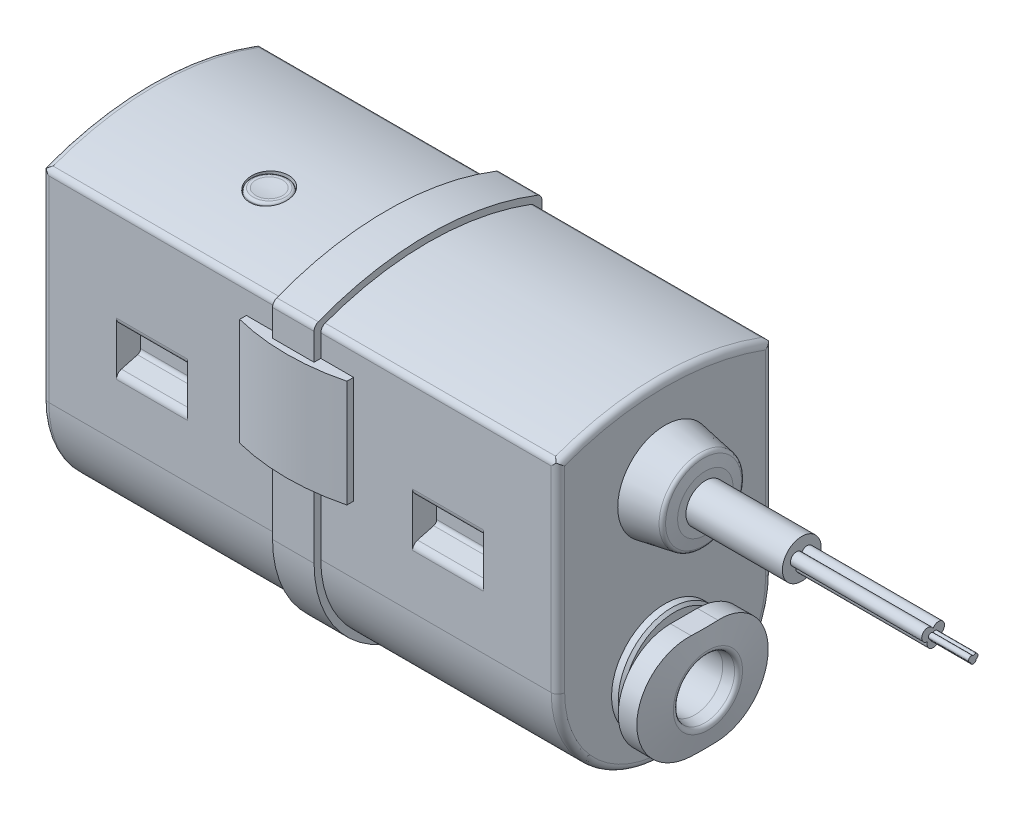
from build123d import *

# Parameters (mm, degrees)
BOSS_EXTRUDE1_DEPTH          = 19.25
BOSS_EXTRUDE1_DEPTH_BACK     = 19.25
CUT_EXTRUDE1_DEPTH           = 25
CUT_EXTRUDE2_DEPTH           = 25
CUT_REVOLVE1_ANGLE           = 90
CUT_REVOLVE1_OTHER_WAY_ANGLE = 90
CUT_REVOLVE2_ANGLE           = 90
CUT_REVOLVE2_OTHER_WAY_ANGLE = 90
CUT_REVOLVE3_ANGLE           = 45
CUT_REVOLVE3_OTHER_WAY_ANGLE = 45
CUT_REVOLVE4_ANGLE           = 45
CUT_REVOLVE4_OTHER_WAY_ANGLE = 45
CUT_EXTRUDE3_DEPTH           = 5.3
CUT_EXTRUDE4_DEPTH           = 5.3
CUT_EXTRUDE5_DEPTH           = 5.3
CUT_EXTRUDE6_DEPTH           = 5.3
BOSS_EXTRUDE2_DEPTH          = 1.55
BOSS_EXTRUDE2_DEPTH_BACK     = 1.55
SKETCH14_W                   = 12
SKETCH14_H                   = 12
CUT_EXTRUDE7_DEPTH           = 2
SKETCH16_W                   = 12
SKETCH16_H                   = 12
CUT_EXTRUDE8_DEPTH           = 2
BOSS_EXTRUDE3_DEPTH          = 4
BOSS_EXTRUDE3_DEPTH_BACK     = 4
BOSS_EXTRUDE4_DEPTH          = 4
BOSS_EXTRUDE4_DEPTH_BACK     = 4
SKETCH19_W                   = 1.45
SKETCH19_H                   = 5
BOSS_EXTRUDE5_DEPTH          = 9.8
BOSS_EXTRUDE6_DEPTH          = 3


with BuildPart() as part:
    # Sketch1 → Boss-Extrude1 (new body, two sides)
    with BuildSketch(Plane(origin=(0, 0, 0), x_dir=(0, 0, -1), z_dir=(1, 0, 0))) as boss_extrude1_sk:
        with BuildLine():
            Line((8, 8), (8, 22.64944168))
            ThreePointArc((8, 22.64944168), (7.910614967, 22.934740381), (7.674418605, 23.118033347))
            ThreePointArc((7.674418605, 23.118033347), (0, 24.5), (-7.674418605, 23.118033347))
            ThreePointArc((-7.674418605, 23.118033347), (-7.910614967, 22.934740381), (-8, 22.64944168))
            Line((-8, 22.64944168), (-8, 8))
            ThreePointArc((-8, 8), (0, 0), (8, 8))
        make_face()
    extrude(amount=BOSS_EXTRUDE1_DEPTH)
    extrude(boss_extrude1_sk.sketch, amount=-BOSS_EXTRUDE1_DEPTH_BACK)

    # Sketch2 → Cut-Extrude1 (cut)
    with BuildSketch(Plane(origin=(0, 0, 0), x_dir=(1, 0, 0), z_dir=(0, 1, 0))):
        with BuildLine():
            Line((0, 18), (0, 8))
            Line((0, 8), (18.75, 8))
            ThreePointArc((18.75, 8), (19.103553391, 7.853553391), (19.25, 7.5))
            Line((19.25, 7.5), (19.25, -7.5))
            ThreePointArc((19.25, -7.5), (19.103553391, -7.853553391), (18.75, -8))
            Line((18.75, -8), (0, -8))
            Line((0, -8), (0, -18))
            Line((0, -18), (29.25, -18))
            Line((29.25, -18), (29.25, 18))
            Line((29.25, 18), (0, 18))
        make_face()
    extrude(amount=CUT_EXTRUDE1_DEPTH, mode=Mode.SUBTRACT)

    # Sketch3 → Cut-Extrude2 (cut)
    with BuildSketch(Plane(origin=(0, 0, 0), x_dir=(1, 0, 0), z_dir=(0, 1, 0))):
        with BuildLine():
            Line((-29.25, 18), (-29.25, -18))
            Line((-29.25, -18), (0, -18))
            Line((0, -18), (0, -8))
            Line((0, -8), (-18.75, -8))
            ThreePointArc((-18.75, -8), (-19.103553391, -7.853553391), (-19.25, -7.5))
            Line((-19.25, -7.5), (-19.25, 7.5))
            ThreePointArc((-19.25, 7.5), (-19.103553391, 7.853553391), (-18.75, 8))
            Line((-18.75, 8), (0, 8))
            Line((0, 8), (0, 18))
            Line((0, 18), (-29.25, 18))
        make_face()
    extrude(amount=CUT_EXTRUDE2_DEPTH, mode=Mode.SUBTRACT)

    # Sketch4 → Cut-Revolve1 (revolve, cut)
    with BuildSketch(Plane.XY):
        with BuildLine():
            Line((-25, 3), (-25, -5.003376947))
            Line((-25, -5.003376947), (-14, -5.003376947))
            Line((-14, -5.003376947), (-14, 0))
            Line((-14, 0), (-18.75, 0))
            ThreePointArc((-18.75, 0), (-19.103553391, 0.146446609), (-19.25, 0.5))
            Line((-19.25, 0.5), (-19.25, 3))
            Line((-19.25, 3), (-25, 3))
        make_face()
    revolve(axis=Axis((-2, 8, 0), (1, 0, 0)), revolution_arc=CUT_REVOLVE1_ANGLE, mode=Mode.SUBTRACT)

    # Sketch4 → Cut-Revolve1 other way (revolve, cut)
    with BuildSketch(Plane.XY):
        with BuildLine():
            Line((-25, 3), (-25, -5.003376947))
            Line((-25, -5.003376947), (-14, -5.003376947))
            Line((-14, -5.003376947), (-14, 0))
            Line((-14, 0), (-18.75, 0))
            ThreePointArc((-18.75, 0), (-19.103553391, 0.146446609), (-19.25, 0.5))
            Line((-19.25, 0.5), (-19.25, 3))
            Line((-19.25, 3), (-25, 3))
        make_face()
    revolve(axis=Axis((-2, 8, 0), (-1, 0, 0)), revolution_arc=CUT_REVOLVE1_OTHER_WAY_ANGLE, mode=Mode.SUBTRACT)

    # Sketch5 → Cut-Revolve2 (revolve, cut)
    with BuildSketch(Plane.XY):
        with BuildLine():
            Line((14, -5.003376947), (25, -5.003376947))
            Line((25, -5.003376947), (25, 3))
            Line((25, 3), (19.25, 3))
            Line((19.25, 3), (19.25, 0.5))
            ThreePointArc((19.25, 0.5), (19.103553391, 0.146446609), (18.75, 0))
            Line((18.75, 0), (14, 0))
            Line((14, 0), (14, -5.003376947))
        make_face()
    revolve(axis=Axis((-2, 8, 0), (1, 0, 0)), revolution_arc=CUT_REVOLVE2_ANGLE, mode=Mode.SUBTRACT)

    # Sketch5 → Cut-Revolve2 other way (revolve, cut)
    with BuildSketch(Plane.XY):
        with BuildLine():
            Line((14, -5.003376947), (25, -5.003376947))
            Line((25, -5.003376947), (25, 3))
            Line((25, 3), (19.25, 3))
            Line((19.25, 3), (19.25, 0.5))
            ThreePointArc((19.25, 0.5), (19.103553391, 0.146446609), (18.75, 0))
            Line((18.75, 0), (14, 0))
            Line((14, 0), (14, -5.003376947))
        make_face()
    revolve(axis=Axis((-2, 8, 0), (-1, 0, 0)), revolution_arc=CUT_REVOLVE2_OTHER_WAY_ANGLE, mode=Mode.SUBTRACT)

    # Sketch6 → Cut-Revolve3 (revolve, cut)
    with BuildSketch(Plane.XY):
        with BuildLine():
            Line((-24.25, 29.5), (-24.25, 22.5))
            Line((-24.25, 22.5), (-19.25, 22.5))
            Line((-19.25, 22.5), (-19.25, 24))
            ThreePointArc((-19.25, 24), (-19.103553391, 24.353553391), (-18.75, 24.5))
            Line((-18.75, 24.5), (-18.75, 29.5))
            Line((-18.75, 29.5), (-24.25, 29.5))
        make_face()
    revolve(axis=Axis((-19.25, 2.5, 0), (-1, 0, 0)), revolution_arc=CUT_REVOLVE3_ANGLE, mode=Mode.SUBTRACT)

    # Sketch6 → Cut-Revolve3 other way (revolve, cut)
    with BuildSketch(Plane.XY):
        with BuildLine():
            Line((-24.25, 29.5), (-24.25, 22.5))
            Line((-24.25, 22.5), (-19.25, 22.5))
            Line((-19.25, 22.5), (-19.25, 24))
            ThreePointArc((-19.25, 24), (-19.103553391, 24.353553391), (-18.75, 24.5))
            Line((-18.75, 24.5), (-18.75, 29.5))
            Line((-18.75, 29.5), (-24.25, 29.5))
        make_face()
    revolve(axis=Axis((-19.25, 2.5, 0), (1, 0, 0)), revolution_arc=CUT_REVOLVE3_OTHER_WAY_ANGLE, mode=Mode.SUBTRACT)

    # Sketch7 → Cut-Revolve4 (revolve, cut)
    with BuildSketch(Plane.XY):
        with BuildLine():
            Line((19.25, 24), (19.25, 22.5))
            Line((19.25, 22.5), (24.25, 22.5))
            Line((24.25, 22.5), (24.25, 29.5))
            Line((24.25, 29.5), (18.75, 29.5))
            Line((18.75, 29.5), (18.75, 24.5))
            ThreePointArc((18.75, 24.5), (19.103553391, 24.353553391), (19.25, 24))
        make_face()
    revolve(axis=Axis((24.25, 2.5, 0), (-1, 0, 0)), revolution_arc=CUT_REVOLVE4_ANGLE, mode=Mode.SUBTRACT)

    # Sketch7 → Cut-Revolve4 other way (revolve, cut)
    with BuildSketch(Plane.XY):
        with BuildLine():
            Line((19.25, 24), (19.25, 22.5))
            Line((19.25, 22.5), (24.25, 22.5))
            Line((24.25, 22.5), (24.25, 29.5))
            Line((24.25, 29.5), (18.75, 29.5))
            Line((18.75, 29.5), (18.75, 24.5))
            ThreePointArc((18.75, 24.5), (19.103553391, 24.353553391), (19.25, 24))
        make_face()
    revolve(axis=Axis((24.25, 2.5, 0), (1, 0, 0)), revolution_arc=CUT_REVOLVE4_OTHER_WAY_ANGLE, mode=Mode.SUBTRACT)

    # Sketch8 → Cut-Extrude3 (cut)
    with BuildSketch(Plane(origin=(-13.7, 0, 0), x_dir=(0, 0, -1), z_dir=(1, 0, 0))):
        with BuildLine():
            Line((-10, 17), (-10, 10))
            Line((-10, 10), (-8, 10))
            Line((-8, 10), (-8, 12.016336506))
            ThreePointArc((-8, 12.016336506), (-7.89667667, 12.320717221), (-7.629409523, 12.499299419))
            Line((-7.629409523, 12.499299419), (-6.422354286, 12.822728895))
            ThreePointArc((-6.422354286, 12.822728895), (-6.261993998, 12.929878214), (-6.2, 13.112506643))
            Line((-6.2, 13.112506643), (-6.2, 14.887493357))
            ThreePointArc((-6.2, 14.887493357), (-6.261993998, 15.070121786), (-6.422354286, 15.177271105))
            Line((-6.422354286, 15.177271105), (-7.629409523, 15.500700581))
            ThreePointArc((-7.629409523, 15.500700581), (-7.89667667, 15.679282779), (-8, 15.983663494))
            Line((-8, 15.983663494), (-8, 17))
            Line((-8, 17), (-10, 17))
        make_face()
    extrude(amount=CUT_EXTRUDE3_DEPTH, mode=Mode.SUBTRACT)

    # Sketch9 → Cut-Extrude4 (cut)
    with BuildSketch(Plane(origin=(-13.7, 0, 0), x_dir=(0, 0, -1), z_dir=(1, 0, 0))):
        with BuildLine():
            Line((6.2, 14.887493357), (6.2, 13.112506643))
            ThreePointArc((6.2, 13.112506643), (6.261993998, 12.929878214), (6.422354286, 12.822728895))
            Line((6.422354286, 12.822728895), (7.629409523, 12.499299419))
            ThreePointArc((7.629409523, 12.499299419), (7.89667667, 12.320717221), (8, 12.016336506))
            Line((8, 12.016336506), (8, 10))
            Line((8, 10), (10, 10))
            Line((10, 10), (10, 17))
            Line((10, 17), (8, 17))
            Line((8, 17), (8, 15.983663494))
            ThreePointArc((8, 15.983663494), (7.89667667, 15.679282779), (7.629409523, 15.500700581))
            Line((7.629409523, 15.500700581), (6.422354286, 15.177271105))
            ThreePointArc((6.422354286, 15.177271105), (6.261993998, 15.070121786), (6.2, 14.887493357))
        make_face()
    extrude(amount=CUT_EXTRUDE4_DEPTH, mode=Mode.SUBTRACT)

    # Sketch10 → Cut-Extrude5 (cut)
    with BuildSketch(Plane(origin=(13.7, 0, 0), x_dir=(0, 0, -1), z_dir=(1, 0, 0))):
        with BuildLine():
            Line((-10, 17), (-10, 10))
            Line((-10, 10), (-8, 10))
            Line((-8, 10), (-8, 12.016336506))
            ThreePointArc((-8, 12.016336506), (-7.89667667, 12.320717221), (-7.629409523, 12.499299419))
            Line((-7.629409523, 12.499299419), (-6.422354286, 12.822728895))
            ThreePointArc((-6.422354286, 12.822728895), (-6.261993998, 12.929878214), (-6.2, 13.112506643))
            Line((-6.2, 13.112506643), (-6.2, 14.887493357))
            ThreePointArc((-6.2, 14.887493357), (-6.261993998, 15.070121786), (-6.422354286, 15.177271105))
            Line((-6.422354286, 15.177271105), (-7.629409523, 15.500700581))
            ThreePointArc((-7.629409523, 15.500700581), (-7.89667667, 15.679282779), (-8, 15.983663494))
            Line((-8, 15.983663494), (-8, 17))
            Line((-8, 17), (-10, 17))
        make_face()
    extrude(amount=-CUT_EXTRUDE5_DEPTH, mode=Mode.SUBTRACT)

    # Sketch11 → Cut-Extrude6 (cut)
    with BuildSketch(Plane(origin=(13.7, 0, 0), x_dir=(0, 0, -1), z_dir=(1, 0, 0))):
        with BuildLine():
            Line((6.2, 14.887493357), (6.2, 13.112506643))
            ThreePointArc((6.2, 13.112506643), (6.261993998, 12.929878214), (6.422354286, 12.822728895))
            Line((6.422354286, 12.822728895), (7.629409523, 12.499299419))
            ThreePointArc((7.629409523, 12.499299419), (7.89667667, 12.320717221), (8, 12.016336506))
            Line((8, 12.016336506), (8, 10))
            Line((8, 10), (10, 10))
            Line((10, 10), (10, 17))
            Line((10, 17), (8, 17))
            Line((8, 17), (8, 15.983663494))
            ThreePointArc((8, 15.983663494), (7.89667667, 15.679282779), (7.629409523, 15.500700581))
            Line((7.629409523, 15.500700581), (6.422354286, 15.177271105))
            ThreePointArc((6.422354286, 15.177271105), (6.261993998, 15.070121786), (6.2, 14.887493357))
        make_face()
    extrude(amount=-CUT_EXTRUDE6_DEPTH, mode=Mode.SUBTRACT)

    # Sketch12 → Boss-Extrude2 (add, two sides)
    with BuildSketch(Plane(origin=(0, 0, 0), x_dir=(0, 0, -1), z_dir=(1, 0, 0))) as boss_extrude2_sk:
        with BuildLine():
            Line((8.5, 8), (8.5, 22.993901532))
            ThreePointArc((8.5, 22.993901532), (8.412861412, 23.275939569), (8.181818182, 23.459672021))
            ThreePointArc((8.181818182, 23.459672021), (0, 25), (-8.181818182, 23.459672021))
            ThreePointArc((-8.181818182, 23.459672021), (-8.412861412, 23.275939569), (-8.5, 22.993901532))
            Line((-8.5, 22.993901532), (-8.5, 8))
            ThreePointArc((-8.5, 8), (0, -0.5), (8.5, 8))
        make_face()
    extrude(amount=BOSS_EXTRUDE2_DEPTH)
    extrude(boss_extrude2_sk.sketch, amount=-BOSS_EXTRUDE2_DEPTH_BACK)

    # Sketch13 → Revolve1 (revolve)
    with BuildSketch(Plane.XY):
        with BuildLine():
            Line((19.25, 8.1), (21.45, 8.1))
            Line((21.45, 8.1), (22.202833893, 8.234689012))
            ThreePointArc((22.202833893, 8.234689012), (22.39584333, 8.358066708), (22.445513271, 8.581690489))
            Line((22.445513271, 8.581690489), (22.04, 10.9))
            Line((22.04, 10.9), (20.65, 10.9))
            Line((20.65, 10.9), (20.65, 8.6))
            Line((20.65, 8.6), (19.95, 8.6))
            Line((19.95, 8.6), (19.95, 9.8))
            Line((19.95, 9.8), (19.75, 10))
            Line((19.75, 10), (19.25, 10))
            Line((19.25, 10), (19.25, 8.1))
        make_face()
    revolve(axis=Axis((22.45, 6, 0), (-1, 0, 0)))

    # Sketch14 → Cut-Extrude7 (cut)
    with BuildSketch(Plane(origin=(22.45, 0, 0), x_dir=(0, 0, -1), z_dir=(1, 0, 0))):
        with Locations((0, 6)):
            Rectangle(SKETCH14_W, SKETCH14_H)
        with BuildLine():
            Line((-1, 2.1), (1, 2.1))
            ThreePointArc((1, 2.1), (4.9, 6), (1, 9.9))
            Line((1, 9.9), (-1, 9.9))
            ThreePointArc((-1, 9.9), (-4.9, 6), (-1, 2.1))
        make_face(mode=Mode.SUBTRACT)
    extrude(amount=-CUT_EXTRUDE7_DEPTH, mode=Mode.SUBTRACT)

    # Sketch15 → Revolve2 (revolve)
    with BuildSketch(Plane.XY):
        with BuildLine():
            Line((-22.202833893, 8.234689012), (-21.45, 8.1))
            Line((-21.45, 8.1), (-19.25, 8.1))
            Line((-19.25, 8.1), (-19.25, 10))
            Line((-19.25, 10), (-19.75, 10))
            Line((-19.75, 10), (-19.95, 9.8))
            Line((-19.95, 9.8), (-19.95, 8.6))
            Line((-19.95, 8.6), (-20.65, 8.6))
            Line((-20.65, 8.6), (-20.65, 10.9))
            Line((-20.65, 10.9), (-22.04, 10.9))
            Line((-22.04, 10.9), (-22.445513271, 8.581690489))
            ThreePointArc((-22.445513271, 8.581690489), (-22.39584333, 8.358066708), (-22.202833893, 8.234689012))
        make_face()
    revolve(axis=Axis((-19.25, 6, 0), (-1, 0, 0)))

    # Sketch16 → Cut-Extrude8 (cut)
    with BuildSketch(Plane(origin=(-22.45, 0, 0), x_dir=(0, 0, -1), z_dir=(1, 0, 0))):
        with Locations((0, 6)):
            Rectangle(SKETCH16_W, SKETCH16_H)
        with BuildLine():
            Line((-1, 2.1), (1, 2.1))
            ThreePointArc((1, 2.1), (4.9, 6), (1, 9.9))
            Line((1, 9.9), (-1, 9.9))
            ThreePointArc((-1, 9.9), (-4.9, 6), (-1, 2.1))
        make_face(mode=Mode.SUBTRACT)
    extrude(amount=CUT_EXTRUDE8_DEPTH, mode=Mode.SUBTRACT)

    # Sketch17 → Boss-Extrude3 (add, two sides)
    with BuildSketch(Plane(origin=(0, 17, 0), x_dir=(1, 0, 0), z_dir=(0, 1, 0))) as boss_extrude3_sk:
        with BuildLine():
            Line((-4, -8), (-4, -8.5))
            ThreePointArc((-4, -8.5), (0, -9), (4, -8.5))
            Line((4, -8.5), (4, -8))
            Line((4, -8), (-4, -8))
        make_face()
    extrude(amount=BOSS_EXTRUDE3_DEPTH)
    extrude(boss_extrude3_sk.sketch, amount=-BOSS_EXTRUDE3_DEPTH_BACK)

    # Sketch18 → Boss-Extrude4 (add, two sides)
    with BuildSketch(Plane(origin=(0, 17, 0), x_dir=(1, 0, 0), z_dir=(0, 1, 0))) as boss_extrude4_sk:
        with BuildLine():
            Line((-4, 8), (4, 8))
            Line((4, 8), (4, 8.5))
            ThreePointArc((4, 8.5), (0, 9), (-4, 8.5))
            Line((-4, 8.5), (-4, 8))
        make_face()
    extrude(amount=BOSS_EXTRUDE4_DEPTH)
    extrude(boss_extrude4_sk.sketch, amount=-BOSS_EXTRUDE4_DEPTH_BACK)

    # Sketch19 → Cut-Revolve5 (revolve, cut)
    with BuildSketch(Plane.XY.offset(2.3)):
        with Locations((-7.275, 24.5)):
            Rectangle(SKETCH19_W, SKETCH19_H)
    revolve(axis=Axis((-8, 22, 2.3), (0, 1, 0)), mode=Mode.SUBTRACT)

    # Sketch20 → Revolve3 (revolve)
    with BuildSketch(Plane.XY.offset(2.3)):
        with BuildLine():
            Line((-7, 24.4), (-6.8, 24.4))
            ThreePointArc((-6.8, 24.4), (-6.658578644, 24.341421356), (-6.6, 24.2))
            Line((-6.6, 24.2), (-6.6, 22))
            Line((-6.6, 22), (-8, 22))
            Line((-8, 22), (-8, 24.3))
            ThreePointArc((-8, 24.3), (-7.498428155, 24.33428155), (-7, 24.4))
        make_face()
    revolve(axis=Axis((-8, 22, 2.3), (0, 1, 0)))

    # Sketch21 → Revolve4 (revolve)
    with BuildSketch(Plane.XY):
        with BuildLine():
            Line((19.25, 18), (19.25, 21.537788324))
            Line((19.25, 21.537788324), (21.872094453, 21.075442326))
            ThreePointArc((21.872094453, 21.075442326), (22.032132034, 20.992132034), (22.115442326, 20.832094453))
            Line((22.115442326, 20.832094453), (22.25, 20.068979963))
            Line((22.25, 20.068979963), (22.25, 19.45))
            Line((22.25, 19.45), (29.45, 19.45))
            Line((29.45, 19.45), (29.45, 18))
            Line((29.45, 18), (19.25, 18))
        make_face()
    revolve(axis=Axis((29.45, 18, 0), (-1, 0, 0)))

    # Sketch22 → Boss-Extrude5 (add)
    with BuildSketch(Plane(origin=(39.25, 0, 0), x_dir=(0, 0, -1), z_dir=(1, 0, 0))):
        with BuildLine():
            ThreePointArc((0, 18.406155281), (-0.777837851, 18.444414727), (-0.424036398, 17.750642401))
            ThreePointArc((-0.424036398, 17.750642401), (0, 17.15), (0.424036398, 17.750642401))
            ThreePointArc((0.424036398, 17.750642401), (0.777837851, 18.444414727), (0, 18.406155281))
        make_face()
    extrude(amount=-BOSS_EXTRUDE5_DEPTH)

    # Sketch23 → Boss-Extrude6 (add)
    with BuildSketch(Plane(origin=(39.25, 0, 0), x_dir=(0, 0, -1), z_dir=(1, 0, 0))):
        with BuildLine():
            ThreePointArc((0, 18.132287566), (-0.320493103, 18.104556692), (-0.19989996, 17.80632503))
            ThreePointArc((-0.19989996, 17.80632503), (0, 17.6), (0.19989996, 17.80632503))
            ThreePointArc((0.19989996, 17.80632503), (0.320493103, 18.104556692), (0, 18.132287566))
        make_face()
    extrude(amount=BOSS_EXTRUDE6_DEPTH)


solid = part.part
